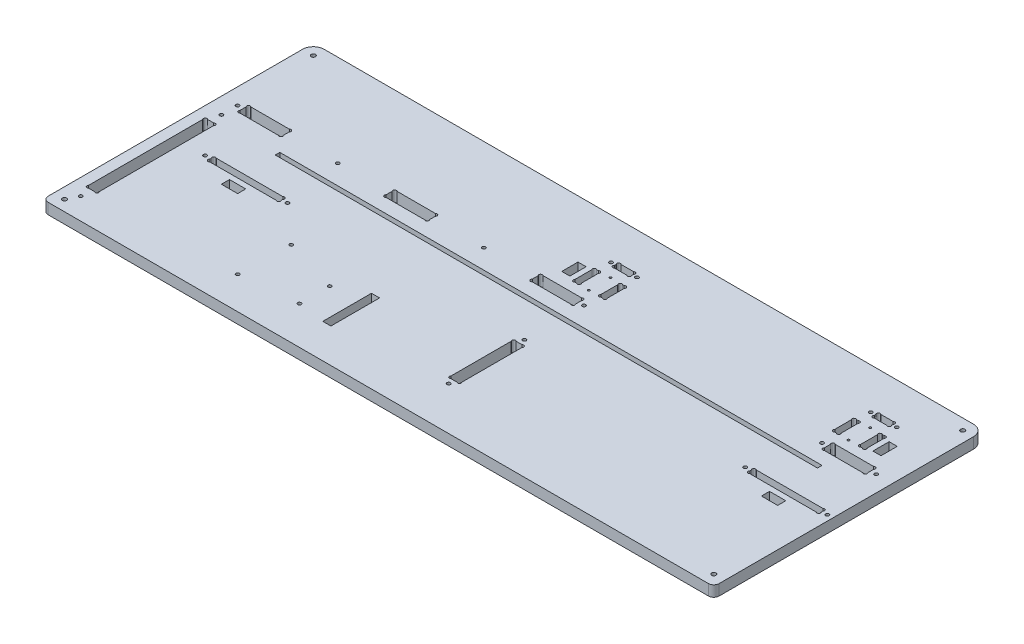
from build123d import *

# Parameters (mm, degrees)
ESQUISSE1_R             = 1.6
EXTRUSION1_DEPTH        = 10
ESQUISSE2_W             = 501
ESQUISSE2_H             = 4.2
ENL_V_MAT_EXTRU_1_DEPTH = 11
ESQUISSE3_R             = 1
ENL_V_MAT_EXTRU_2_DEPTH = 11
CONG_1_R                = 5
ESQUISSE4_R             = 2
ENL_V_MAT_EXTRU_3_DEPTH = 11
ESQUISSE5_R             = 1.59
ENL_V_MAT_EXTRU_4_DEPTH = 11
ESQUISSE6_W             = 15
ESQUISSE6_H             = 7.5
ESQUISSE6_W_2           = 7.5
ESQUISSE6_H_2           = 15
ESQUISSE6_H_3           = 45
ENL_V_MAT_EXTRU_5_DEPTH = 11


with BuildPart() as part:
    # Esquisse1 → Extrusion1 (new body)
    with BuildSketch(Plane(origin=(0, 0, 0), x_dir=(1, 0, 0), z_dir=(0, 1, 0))):
        with BuildLine():
            Line((10, 250), (610, 250))
            ThreePointArc((610, 250), (617.071067812, 247.071067812), (620, 240))
            Line((620, 240), (620, 0))
            Line((620, 0), (0, 0))
            Line((0, 0), (0, 240))
            ThreePointArc((0, 240), (2.928932188, 247.071067812), (10, 250))
        make_face()
        with Locations(Location((313, 212, 0), (0, 0, 270))):  # turned: the seam where the file's is
            Circle(ESQUISSE1_R, mode=Mode.SUBTRACT)
        with Locations(Location((337, 212, 0), (0, 0, 90))):  # turned: the seam where the file's is
            Circle(ESQUISSE1_R, mode=Mode.SUBTRACT)
        with Locations(Location((553, 212, 0), (0, 0, 270))):  # turned: the seam where the file's is
            Circle(ESQUISSE1_R, mode=Mode.SUBTRACT)
        with Locations(Location((577, 212, 0), (0, 0, 90))):  # turned: the seam where the file's is
            Circle(ESQUISSE1_R, mode=Mode.SUBTRACT)
        with Locations(Location((555, 165, 0), (0, 0, 270))):  # turned: the seam where the file's is
            Circle(ESQUISSE1_R, mode=Mode.SUBTRACT)
        with Locations(Location((605, 165, 0), (0, 0, 90))):  # turned: the seam where the file's is
            Circle(ESQUISSE1_R, mode=Mode.SUBTRACT)
        with Locations(Location((335, 165, 0), (0, 0, 90))):  # turned: the seam where the file's is
            Circle(ESQUISSE1_R, mode=Mode.SUBTRACT)
        with Locations(Location((15, 165, 0), (0, 0, 270))):  # turned: the seam where the file's is
            Circle(ESQUISSE1_R, mode=Mode.SUBTRACT)
        with Locations(Location((242.5, 165, 0), (0, 0, 270))):  # turned: the seam where the file's is
            Circle(ESQUISSE1_R, mode=Mode.SUBTRACT)
        with Locations(Location((107.5, 165, 0), (0, 0, 90))):  # turned: the seam where the file's is
            Circle(ESQUISSE1_R, mode=Mode.SUBTRACT)
        with Locations(Location((15, 20, 0), (0, 0, 270))):  # turned: the seam where the file's is
            Circle(ESQUISSE1_R, mode=Mode.SUBTRACT)
        with Locations(Location((15, 150, 0), (0, 0, 90))):  # turned: the seam where the file's is
            Circle(ESQUISSE1_R, mode=Mode.SUBTRACT)
        with Locations(Location((335, 40, 0), (0, 0, 270))):  # turned: the seam where the file's is
            Circle(ESQUISSE1_R, mode=Mode.SUBTRACT)
        with Locations(Location((335, 110, 0), (0, 0, 90))):  # turned: the seam where the file's is
            Circle(ESQUISSE1_R, mode=Mode.SUBTRACT)
        with Locations(Location((615, 110, 0), (0, 0, 270))):  # turned: the seam where the file's is
            Circle(ESQUISSE1_R, mode=Mode.SUBTRACT)
        with Locations(Location((539, 110, 0), (0, 0, 90))):  # turned: the seam where the file's is
            Circle(ESQUISSE1_R, mode=Mode.SUBTRACT)
        with Locations(Location((116, 110, 0), (0, 0, 270))):  # turned: the seam where the file's is
            Circle(ESQUISSE1_R, mode=Mode.SUBTRACT)
        with Locations(Location((40, 110, 0), (0, 0, 90))):  # turned: the seam where the file's is
            Circle(ESQUISSE1_R, mode=Mode.SUBTRACT)
        with BuildLine():
            Line((317, 211.2627417), (317, 212.7372583))
            ThreePointArc((317, 212.7372583), (317, 215), (319.2627417, 215))
            Line((319.2627417, 215), (330.7372583, 215))
            ThreePointArc((330.7372583, 215), (333, 215), (333, 212.7372583))
            Line((333, 212.7372583), (333, 211.2627417))
            ThreePointArc((333, 211.2627417), (333, 209), (330.737258301, 209))
            Line((330.737258301, 209), (319.262741699, 209))
            ThreePointArc((319.262741699, 209), (316.999999999, 209.000000001), (317, 211.2627417))
        make_face(mode=Mode.SUBTRACT)
        with BuildLine():
            Line((312.262741699, 179.5), (313.737258301, 179.5))
            ThreePointArc((313.737258301, 179.5), (316.000000001, 179.500000001), (316, 181.762741701))
            Line((316, 181.762741701), (316, 197.237258299))
            ThreePointArc((316, 197.237258299), (316.000000001, 199.499999999), (313.737258301, 199.5))
            Line((313.737258301, 199.5), (312.262741699, 199.5))
            ThreePointArc((312.262741699, 199.5), (309.999999999, 199.499999999), (310, 197.237258299))
            Line((310, 197.237258299), (310, 181.762741701))
            ThreePointArc((310, 181.762741701), (309.999999999, 179.500000001), (312.262741699, 179.5))
        make_face(mode=Mode.SUBTRACT)
        with BuildLine():
            Line((334, 181.762741701), (334, 197.2372583))
            ThreePointArc((334, 197.2372583), (334, 199.5), (336.2627417, 199.5))
            Line((336.2627417, 199.5), (337.7372583, 199.5))
            ThreePointArc((337.7372583, 199.5), (340, 199.5), (340, 197.2372583))
            Line((340, 197.2372583), (340, 181.762741701))
            ThreePointArc((340, 181.762741701), (340.000000001, 179.500000001), (337.737258301, 179.5))
            Line((337.737258301, 179.5), (336.262741699, 179.5))
            ThreePointArc((336.262741699, 179.5), (333.999999999, 179.500000001), (334, 181.762741701))
        make_face(mode=Mode.SUBTRACT)
        with BuildLine():
            Line((552.2627417, 179.5), (553.7372583, 179.5))
            ThreePointArc((553.7372583, 179.5), (556, 179.5), (556, 181.7627417))
            Line((556, 181.7627417), (556, 197.2372583))
            ThreePointArc((556, 197.2372583), (556, 199.5), (553.7372583, 199.5))
            Line((553.7372583, 199.5), (552.2627417, 199.5))
            ThreePointArc((552.2627417, 199.5), (550, 199.5), (550, 197.2372583))
            Line((550, 197.2372583), (550, 181.7627417))
            ThreePointArc((550, 181.7627417), (550, 179.5), (552.2627417, 179.5))
        make_face(mode=Mode.SUBTRACT)
        with BuildLine():
            Line((574, 181.7627417), (574, 197.2372583))
            ThreePointArc((574, 197.2372583), (574, 199.5), (576.2627417, 199.5))
            Line((576.2627417, 199.5), (577.7372583, 199.5))
            ThreePointArc((577.7372583, 199.5), (580, 199.5), (580, 197.2372583))
            Line((580, 197.2372583), (580, 181.7627417))
            ThreePointArc((580, 181.7627417), (580, 179.5), (577.7372583, 179.5))
            Line((577.7372583, 179.5), (576.2627417, 179.5))
            ThreePointArc((576.2627417, 179.5), (574, 179.5), (574, 181.7627417))
        make_face(mode=Mode.SUBTRACT)
        with BuildLine():
            Line((559.2627417, 209), (570.7372583, 209))
            ThreePointArc((570.7372583, 209), (573, 209), (573, 211.2627417))
            Line((573, 211.2627417), (573, 212.7372583))
            ThreePointArc((573, 212.7372583), (573, 215), (570.7372583, 215))
            Line((570.7372583, 215), (559.2627417, 215))
            ThreePointArc((559.2627417, 215), (557, 215), (557, 212.7372583))
            Line((557, 212.7372583), (557, 211.2627417))
            ThreePointArc((557, 211.2627417), (557, 209), (559.2627417, 209))
        make_face(mode=Mode.SUBTRACT)
        with BuildLine():
            Line((560, 167.7372583), (560, 162.2627417))
            ThreePointArc((560, 162.2627417), (560, 160), (562.2627417, 160))
            Line((562.2627417, 160), (597.7372583, 160))
            ThreePointArc((597.7372583, 160), (600, 160), (600, 162.2627417))
            Line((600, 162.2627417), (600, 167.7372583))
            ThreePointArc((600, 167.7372583), (600, 170), (597.7372583, 170))
            Line((597.7372583, 170), (562.2627417, 170))
            ThreePointArc((562.2627417, 170), (560, 170), (560, 167.7372583))
        make_face(mode=Mode.SUBTRACT)
        with BuildLine():
            Line((292.2627417, 160), (327.7372583, 160))
            ThreePointArc((327.7372583, 160), (330, 160), (330, 162.2627417))
            Line((330, 162.2627417), (330, 167.7372583))
            ThreePointArc((330, 167.7372583), (330, 170), (327.7372583, 170))
            Line((327.7372583, 170), (292.2627417, 170))
            ThreePointArc((292.2627417, 170), (290, 170), (290, 167.7372583))
            Line((290, 167.7372583), (290, 162.2627417))
            ThreePointArc((290, 162.2627417), (290, 160), (292.2627417, 160))
        make_face(mode=Mode.SUBTRACT)
        with BuildLine():
            Line((20, 167.7372583), (20, 162.2627417))
            ThreePointArc((20, 162.2627417), (20, 160), (22.2627417, 160))
            Line((22.2627417, 160), (57.7372583, 160))
            ThreePointArc((57.7372583, 160), (60, 160), (60, 162.2627417))
            Line((60, 162.2627417), (60, 167.7372583))
            ThreePointArc((60, 167.7372583), (60, 170), (57.7372583, 170))
            Line((57.7372583, 170), (22.2627417, 170))
            ThreePointArc((22.2627417, 170), (20, 170), (20, 167.7372583))
        make_face(mode=Mode.SUBTRACT)
        with BuildLine():
            Line((155, 167.7372583), (155, 162.2627417))
            ThreePointArc((155, 162.2627417), (155, 160), (157.2627417, 160))
            Line((157.2627417, 160), (192.7372583, 160))
            ThreePointArc((192.7372583, 160), (195, 160), (195, 162.2627417))
            Line((195, 162.2627417), (195, 167.7372583))
            ThreePointArc((195, 167.7372583), (195, 170), (192.7372583, 170))
            Line((192.7372583, 170), (157.2627417, 170))
            ThreePointArc((157.2627417, 170), (155, 170), (155, 167.7372583))
        make_face(mode=Mode.SUBTRACT)
        with BuildLine():
            Line((12.2627417, 30), (17.7372583, 30))
            ThreePointArc((17.7372583, 30), (20, 30), (20, 32.2627417))
            Line((20, 32.2627417), (20, 137.7372583))
            ThreePointArc((20, 137.7372583), (20, 140), (17.7372583, 140))
            Line((17.7372583, 140), (12.2627417, 140))
            ThreePointArc((12.2627417, 140), (10, 140), (10, 137.7372583))
            Line((10, 137.7372583), (10, 32.2627417))
            ThreePointArc((10, 32.2627417), (10, 30), (12.2627417, 30))
        make_face(mode=Mode.SUBTRACT)
        with BuildLine():
            Line((337.7372583, 45), (332.2627417, 45))
            ThreePointArc((332.2627417, 45), (330, 45), (330, 47.2627417))
            Line((330, 47.2627417), (330, 102.7372583))
            ThreePointArc((330, 102.7372583), (330, 105), (332.2627417, 105))
            Line((332.2627417, 105), (337.7372583, 105))
            ThreePointArc((337.7372583, 105), (340, 105), (340, 102.7372583))
            Line((340, 102.7372583), (340, 47.2627417))
            ThreePointArc((340, 47.2627417), (340, 45), (337.7372583, 45))
        make_face(mode=Mode.SUBTRACT)
        with BuildLine():
            Line((610, 109.2627417), (610, 110.7372583))
            ThreePointArc((610, 110.7372583), (610, 113), (607.7372583, 113))
            Line((607.7372583, 113), (546.2627417, 113))
            ThreePointArc((546.2627417, 113), (544, 113), (544, 110.7372583))
            Line((544, 110.7372583), (544, 109.2627417))
            ThreePointArc((544, 109.2627417), (544, 107), (546.2627417, 107))
            Line((546.2627417, 107), (607.7372583, 107))
            ThreePointArc((607.7372583, 107), (610, 107), (610, 109.2627417))
        make_face(mode=Mode.SUBTRACT)
        with BuildLine():
            Line((108.7372583, 113), (47.2627417, 113))
            ThreePointArc((47.2627417, 113), (45, 113), (45, 110.7372583))
            Line((45, 110.7372583), (45, 109.2627417))
            ThreePointArc((45, 109.2627417), (45, 107), (47.2627417, 107))
            Line((47.2627417, 107), (108.7372583, 107))
            ThreePointArc((108.7372583, 107), (111, 107), (111, 109.2627417))
            Line((111, 109.2627417), (111, 110.7372583))
            ThreePointArc((111, 110.7372583), (111, 113), (108.7372583, 113))
        make_face(mode=Mode.SUBTRACT)
    extrude(amount=EXTRUSION1_DEPTH)

    # Esquisse2 → Enlèv. mat.-Extru.1 (cut, through all)
    with BuildSketch(Plane(origin=(0, 10, 0), x_dir=(-1, 0, 0), z_dir=(0, 1, 0))):
        with Locations((-322.5, -144.9)):
            Rectangle(ESQUISSE2_W, ESQUISSE2_H)
    extrude(amount=-ENL_V_MAT_EXTRU_1_DEPTH, mode=Mode.SUBTRACT)

    # Esquisse3 → Enlèv. mat.-Extru.2 (cut, through all)
    with BuildSketch(Plane(origin=(0, 10, 0), x_dir=(1, 0, 0), z_dir=(0, 1, 0))):
        with Locations(Location((565, 179.5, 0), (0, 0, 270))):  # turned: the seam where the file's is
            Circle(ESQUISSE3_R)
        with Locations(Location((565, 199.5, 0), (0, 0, 270))):  # turned: the seam where the file's is
            Circle(ESQUISSE3_R)
        with Locations(Location((325, 179.5, 0), (0, 0, 270))):  # turned: the seam where the file's is
            Circle(ESQUISSE3_R)
        with Locations(Location((325, 199.5, 0), (0, 0, 270))):  # turned: the seam where the file's is
            Circle(ESQUISSE3_R)
    extrude(amount=-ENL_V_MAT_EXTRU_2_DEPTH, mode=Mode.SUBTRACT)

    # Congé1
    cong_1_edges = [part.edges().sort_by_distance(p)[0] for p in [
        (620, 5, 0),
        (0, 5, 0),
    ]]
    fillet(cong_1_edges, radius=CONG_1_R)

    # Esquisse4 → Enlèv. mat.-Extru.3 (cut, through all)
    with BuildSketch(Plane.XZ):
        with Locations(Location((10, -10, 0), (0, 0, 270))):  # turned: the seam where the file's is
            Circle(ESQUISSE4_R)
        with Locations(Location((610, -10, 0), (0, 0, 270))):  # turned: the seam where the file's is
            Circle(ESQUISSE4_R)
        with Locations(Location((610, -240, 0), (0, 0, 270))):  # turned: the seam where the file's is
            Circle(ESQUISSE4_R)
        with Locations(Location((10, -240, 0), (0, 0, 270))):  # turned: the seam where the file's is
            Circle(ESQUISSE4_R)
    extrude(amount=-ENL_V_MAT_EXTRU_3_DEPTH, mode=Mode.SUBTRACT)

    # Esquisse5 → Enlèv. mat.-Extru.4 (cut, through all)
    with BuildSketch(Plane(origin=(0, 10, 0), x_dir=(1, 0, 0), z_dir=(0, 1, 0))):
        with Locations(Location((151.27, 78.26, 0), (0, 0, 270))):  # turned: the seam where the file's is
            Circle(ESQUISSE5_R)
        with Locations(Location((150, 30, 0), (0, 0, 270))):  # turned: the seam where the file's is
            Circle(ESQUISSE5_R)
        with Locations(Location((202.07, 63.02, 0), (0, 0, 270))):  # turned: the seam where the file's is
            Circle(ESQUISSE5_R)
        with Locations(Location((202.07, 35.08, 0), (0, 0, 270))):  # turned: the seam where the file's is
            Circle(ESQUISSE5_R)
    extrude(amount=-ENL_V_MAT_EXTRU_4_DEPTH, mode=Mode.SUBTRACT)

    # Esquisse6 → Enlèv. mat.-Extru.5 (cut, through all)
    with BuildSketch(Plane(origin=(0, 10, 0), x_dir=(1, 0, 0), z_dir=(0, 1, 0))):
        with Locations((577, 98.25)):
            Rectangle(ESQUISSE6_W, ESQUISSE6_H)
        with Locations((588.75, 189.5)):
            Rectangle(ESQUISSE6_W_2, ESQUISSE6_H_2)
        with Locations((301.25, 189.5)):
            Rectangle(ESQUISSE6_W_2, ESQUISSE6_H_2)
        with Locations((230.82, 54.13)):
            Rectangle(ESQUISSE6_W_2, ESQUISSE6_H_3)
        with Locations((78, 98.25)):
            Rectangle(ESQUISSE6_W, ESQUISSE6_H)
    extrude(amount=-ENL_V_MAT_EXTRU_5_DEPTH, mode=Mode.SUBTRACT)


solid = part.part
